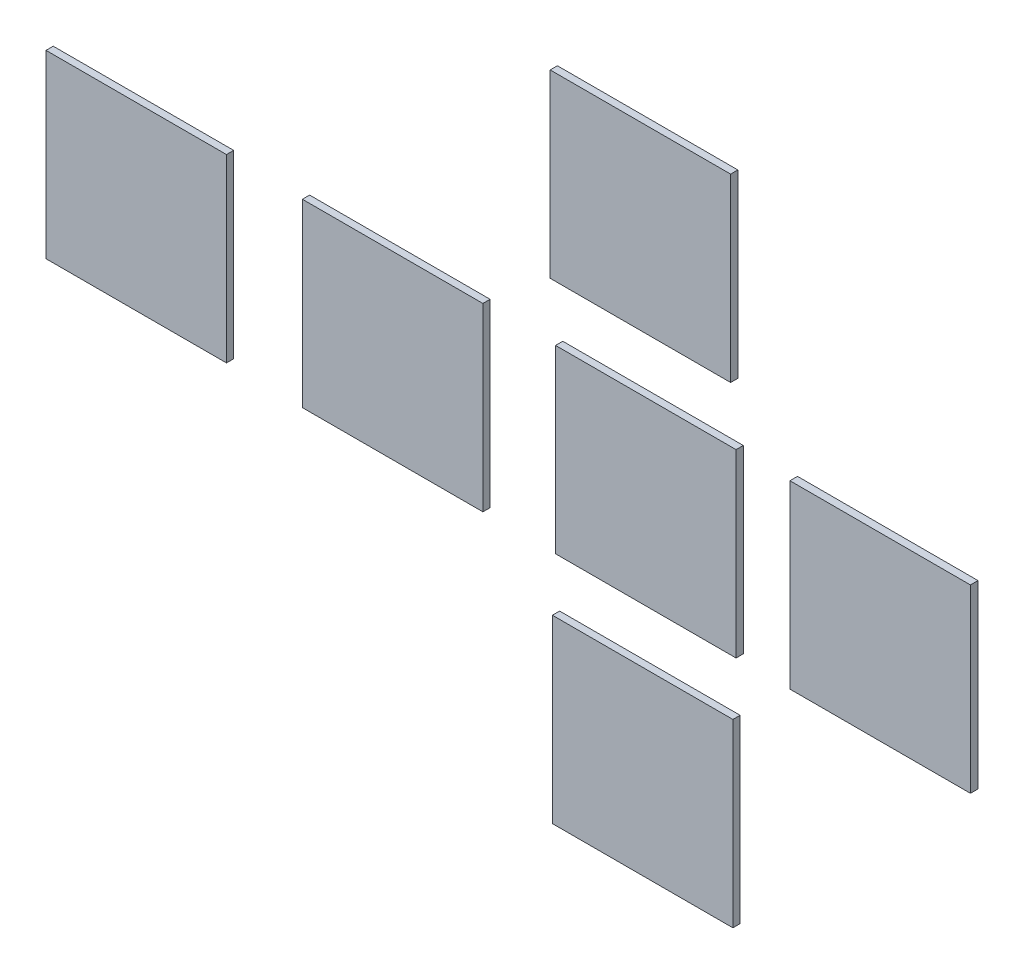
from build123d import *

# Parameters (mm, degrees)
CROQUIS2_W                   = 500
CROQUIS2_H                   = 500
SALIENTE_EXTRUIR1_DEPTH      = 20
SALIENTE_EXTRUIR1_DEPTH_BACK = 1
CROQUIS3_W                   = 500
CROQUIS3_H                   = 500
SALIENTE_EXTRUIR4_DEPTH      = 20
CROQUIS6_W                   = 500
CROQUIS6_H                   = 500
SALIENTE_EXTRUIR8_DEPTH      = 20
SALIENTE_EXTRUIR8_2_DEPTH    = 20
SALIENTE_EXTRUIR8_3_DEPTH    = 20
SALIENTE_EXTRUIR8_4_DEPTH    = 20


with BuildPart() as part:
    # Croquis2 → Saliente-Extruir1 (new body, two sides)
    with BuildSketch(Plane.XY) as saliente_extruir1_sk:
        Rectangle(CROQUIS2_W, CROQUIS2_H)
    extrude(amount=SALIENTE_EXTRUIR1_DEPTH)
    extrude(saliente_extruir1_sk.sketch, amount=-SALIENTE_EXTRUIR1_DEPTH_BACK)


with BuildPart() as body_2:
    # Croquis3 → Saliente-Extruir4 (new body)
    with BuildSketch(Plane.XY):
        with Locations((-649.260038847, 0)):
            Rectangle(CROQUIS3_W, CROQUIS3_H)
    extrude(amount=SALIENTE_EXTRUIR4_DEPTH)


with BuildPart() as body_3:
    # Croquis6 → Saliente-Extruir8 (new body)
    with BuildSketch(Plane.XY):
        with Locations((-2060.998610557, 2.097428348)):
            Rectangle(CROQUIS6_W, CROQUIS6_H)
    extrude(amount=SALIENTE_EXTRUIR8_DEPTH)


with BuildPart() as body_4:
    # Croquis6 → Saliente-Extruir8 2 (new body)
    with BuildSketch(Plane.XY):
        with Locations((-1350.647175862, 0.020163499)):
            Rectangle(CROQUIS6_W, CROQUIS6_H)
    extrude(amount=SALIENTE_EXTRUIR8_2_DEPTH)


with BuildPart() as body_5:
    # Croquis6 → Saliente-Extruir8 3 (new body)
    with BuildSketch(Plane.XY):
        with Locations((-664.251974106, 653.510640464)):
            Rectangle(CROQUIS6_W, CROQUIS6_H)
    extrude(amount=SALIENTE_EXTRUIR8_3_DEPTH)


with BuildPart() as body_6:
    # Croquis6 → Saliente-Extruir8 4 (new body)
    with BuildSketch(Plane.XY):
        with Locations((-658.036665945, -651.704073477)):
            Rectangle(CROQUIS6_W, CROQUIS6_H)
    extrude(amount=SALIENTE_EXTRUIR8_4_DEPTH)


solid = Compound([part.part, body_2.part, body_3.part, body_4.part, body_5.part, body_6.part])
